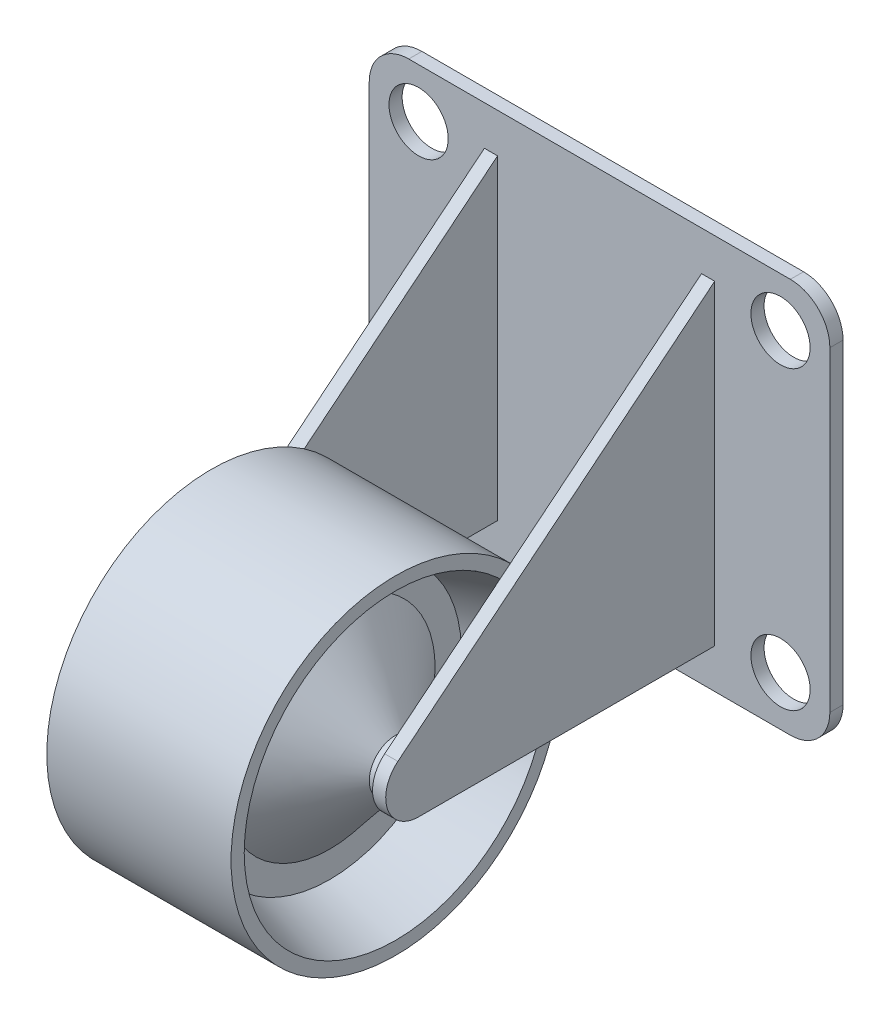
from build123d import *

# Parameters (mm, degrees)
SKETCH_1_W          = 35
SKETCH_1_H          = 30
EXTRUDE_1_DEPTH     = 1
FILLET_1_R          = 3
SKETCH_2_R          = 2.25
CUT_EXTRUDE_1_DEPTH = 2
SKETCH_3_W          = 1
SKETCH_3_H          = 25
EXTRUDE_2_DEPTH     = 30
CUT_EXTRUDE_2_DEPTH = 27.25
EXTRUDE_3_REACH     = 27.25
SKETCH_5_R          = 2
SKETCH_6_R          = 12.5
EXTRUDE_4_DEPTH     = 7


with BuildPart() as part:
    # ｽｹｯﾁ1 → ﾎﾞｽ - 押し出し1 (new body)
    with BuildSketch(Plane.XY):
        with Locations((17.5, -15)):
            Rectangle(SKETCH_1_W, SKETCH_1_H)
    extrude(amount=EXTRUDE_1_DEPTH)

    # ﾌｨﾚｯﾄ1
    fillet_1_edges = [part.edges().sort_by_distance(p)[0] for p in [
        (0, 0, 0.5),
        (35, 0, 0.5),
        (35, -30, 0.5),
        (0, -30, 0.5),
    ]]
    fillet(fillet_1_edges, radius=FILLET_1_R)

    # ｽｹｯﾁ2 → ｶｯﾄ - 押し出し1 (cut, through all)
    with BuildSketch(Plane.XY.offset(1)):
        with Locations((31.25, -3.75)):
            Circle(SKETCH_2_R)
        with Locations((31.25, -26.25)):
            Circle(SKETCH_2_R)
        with Locations((3.75, -26.25)):
            Circle(SKETCH_2_R)
        with Locations((3.75, -3.75)):
            Circle(SKETCH_2_R)
    extrude(amount=-CUT_EXTRUDE_1_DEPTH, mode=Mode.SUBTRACT)

    # ｽｹｯﾁ3 → ﾎﾞｽ - 押し出し2 (add)
    with BuildSketch(Plane(origin=(0, 0, 0), x_dir=(1, 0, 0), z_dir=(0, 1, 0))):
        with Locations((9.25, -13.5)):
            Rectangle(SKETCH_3_W, SKETCH_3_H)
        with Locations((25.75, -13.5)):
            Rectangle(SKETCH_3_W, SKETCH_3_H)
    extrude(amount=-EXTRUDE_2_DEPTH)

    # ｽｹｯﾁ4 → ｶｯﾄ - 押し出し2 (cut, through all)
    with BuildSketch(Plane(origin=(26.25, 0, 0), x_dir=(0, 0, -1), z_dir=(1, 0, 0))):
        with BuildLine():
            ThreePointArc((-26, -24.5), (-25.757311392, -23.425502313), (-25.076363776, -22.559619304))
            Line((-25.076363776, -22.559619304), (-1, -3))
            Line((-1, -3), (-1, 0))
            Line((-1, 0), (-26, 0))
            Line((-26, 0), (-26, -24.5))
        make_face()
        with BuildLine():
            ThreePointArc((-23.5, -27), (-25.267766953, -26.267766953), (-26, -24.5))
            Line((-26, -24.5), (-26, -30))
            Line((-26, -30), (-1, -30))
            Line((-1, -30), (-1, -27))
            Line((-1, -27), (-23.5, -27))
        make_face()
    extrude(amount=-CUT_EXTRUDE_2_DEPTH, mode=Mode.SUBTRACT)

    # ｽｹｯﾁ5 → ﾎﾞｽ - 押し出し3 (add, up to next)
    with BuildSketch(Plane.ZY.offset(-25.25), mode=Mode.PRIVATE) as extrude_3_sk1:
        with Locations((23.5, -24.5)):
            Circle(SKETCH_5_R)
    extrude_3_tool1 = extrude(extrude_3_sk1.sketch, amount=EXTRUDE_3_REACH, mode=Mode.PRIVATE) - part.part
    add(extrude_3_tool1.solids().sort_by_distance((25.25, -24.5, 23.5))[0])

    # ｽｹｯﾁ6 → ﾎﾞｽ - 押し出し4 (add, symmetric)
    with BuildSketch(Plane(origin=(17.5, 0, 0), x_dir=(0, 0, -1), z_dir=(1, 0, 0))):
        with Locations((-23.5, -24.5)):
            Circle(SKETCH_6_R)
    extrude(amount=EXTRUDE_4_DEPTH, both=True)

    # ｽｹｯﾁ7 → ｶｯﾄ - 回転1 (revolve, cut)
    with BuildSketch(Plane(origin=(0, 0, 23.5), x_dir=(-1, 0, 0), z_dir=(0, 0, -1))):
        Polygon((-24.5, -13), (-19.5, -14.5), (-19.5, -16.5), (-24.5, -22.5), align=None)
        Polygon((-10.5, -13), (-15.5, -14.5), (-15.5, -16.5), (-10.5, -22.5), align=None)
    revolve(axis=Axis((-9.093978877, -24.5, 23.5), (1, 0, 0)), mode=Mode.SUBTRACT)


solid = part.part
